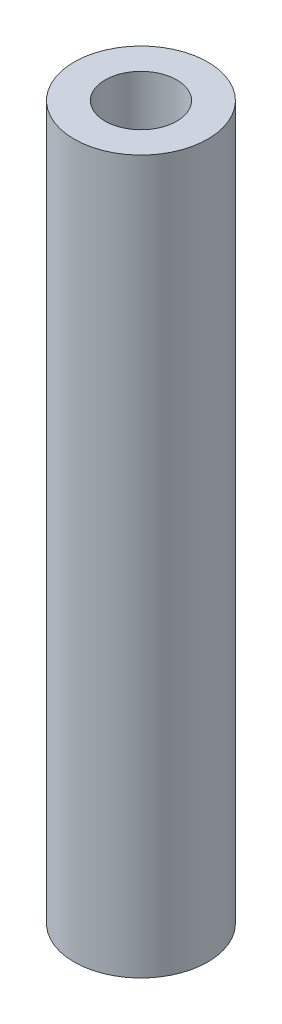
from build123d import *

# Parameters (mm, degrees)
SKETCH1_R           = 4.7625
SKETCH1_R_2         = 2.5527
BOSS_EXTRUDE1_DEPTH = 25.4


with BuildPart() as part:
    # Sketch1 → Boss-Extrude1 (new body, symmetric)
    with BuildSketch(Plane(origin=(0, 0, 0), x_dir=(1, 0, 0), z_dir=(0, 1, 0))):
        Circle(SKETCH1_R)
        Circle(SKETCH1_R_2, mode=Mode.SUBTRACT)
    extrude(amount=BOSS_EXTRUDE1_DEPTH, both=True)


solid = part.part
